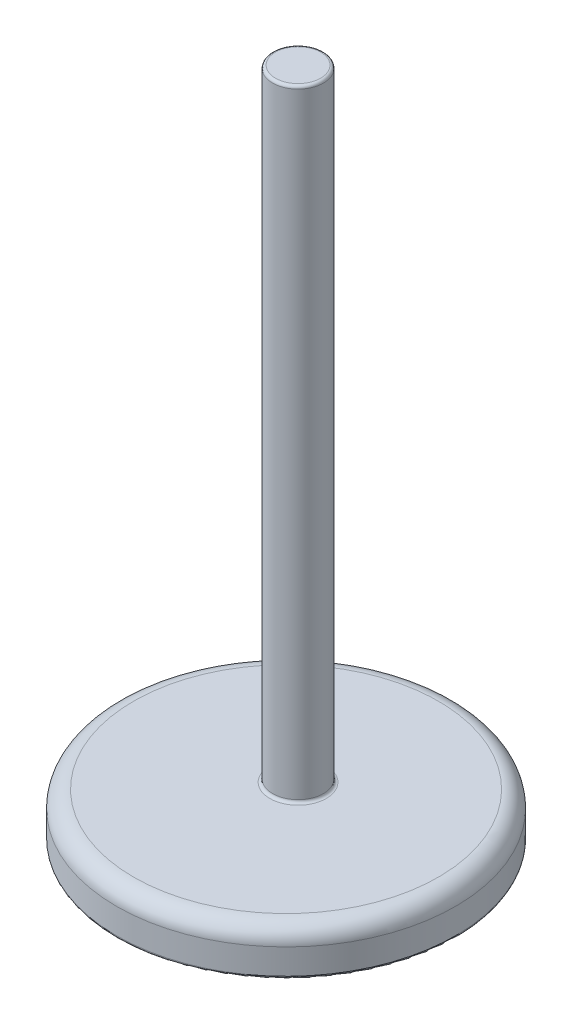
from build123d import *

# Parameters (mm, degrees)
SKETCH1_R           = 60
BOSS_EXTRUDE1_DEPTH = 16
SKETCH2_R           = 9
BOSS_EXTRUDE2_DEPTH = 220
FILLET1_R           = 6
FILLET2_R           = 1


with BuildPart() as part:
    # Sketch1 → Boss-Extrude1 (new body)
    with BuildSketch(Plane(origin=(0, 0, 0), x_dir=(1, 0, 0), z_dir=(0, 1, 0))):
        Circle(SKETCH1_R)
    extrude(amount=BOSS_EXTRUDE1_DEPTH)

    # Sketch2 → Boss-Extrude2 (add)
    with BuildSketch(Plane(origin=(0, 16, 0), x_dir=(1, 0, 0), z_dir=(0, 1, 0))):
        with Locations((0, 4.253298282)):
            Circle(SKETCH2_R)
    extrude(amount=BOSS_EXTRUDE2_DEPTH)

    # Fillet1
    fillet1_edges = [part.edges().sort_by_distance(p)[0] for p in [
        (-60, 16, 0),
    ]]
    fillet(fillet1_edges, radius=FILLET1_R)

    # Fillet2
    fillet2_edges = [part.edges().sort_by_distance(p)[0] for p in [
        (-60, 0, 0),
        (-9, 16, -4.253298282),
        (-9, 236, -4.253298282),
    ]]
    fillet(fillet2_edges, radius=FILLET2_R)


solid = part.part
